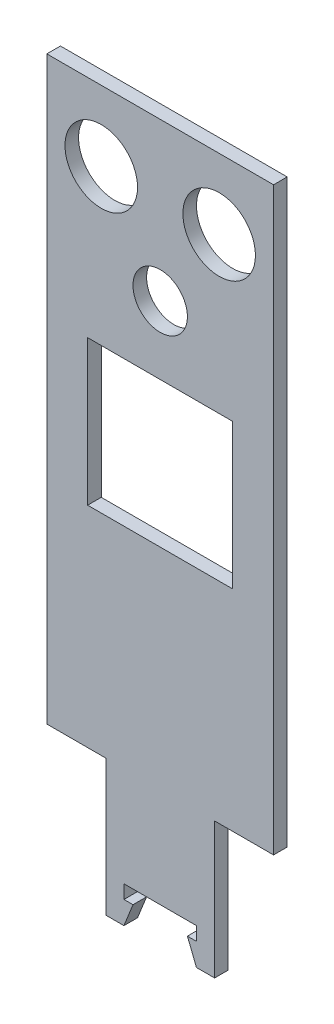
from build123d import *

# Parameters (mm, degrees)
MODEL_R                 = 6
MODEL_R_2               = 8
MODEL_W                 = 32
MODEL_H                 = 32
SALIENTE_EXTRUIR1_DEPTH = 3


with BuildPart() as part:
    # Model → Saliente-Extruir1 (new body)
    with BuildSketch(Plane.XY):
        Polygon((58.7498, 90.00776192), (58.7498, -37.99223808), (45.7498, -37.99223808), (45.7498, -67.99223808), (41.7498, -67.99223808), (39.7498, -62.99223808), (41.7498, -62.99223808), (41.7498, -59.99223808), (25.7498, -59.99223808), (25.7498, -62.99223808), (27.7498, -62.99223808), (25.7498, -67.99223808), (21.7498, -67.99223808), (21.7498, -37.99223808), (8.7498, -37.99223808), (8.7498, 90.00776192), align=None)
        with Locations((33.7498, 55.30776192)):
            Circle(MODEL_R, mode=Mode.SUBTRACT)
        with Locations((20.7498, 74.50776192)):
            Circle(MODEL_R_2, mode=Mode.SUBTRACT)
        with Locations((46.7498, 74.50776192)):
            Circle(MODEL_R_2, mode=Mode.SUBTRACT)
        with Locations((33.7498, 24.30776192)):
            Rectangle(MODEL_W, MODEL_H, mode=Mode.SUBTRACT)
    extrude(amount=SALIENTE_EXTRUIR1_DEPTH)


solid = part.part
